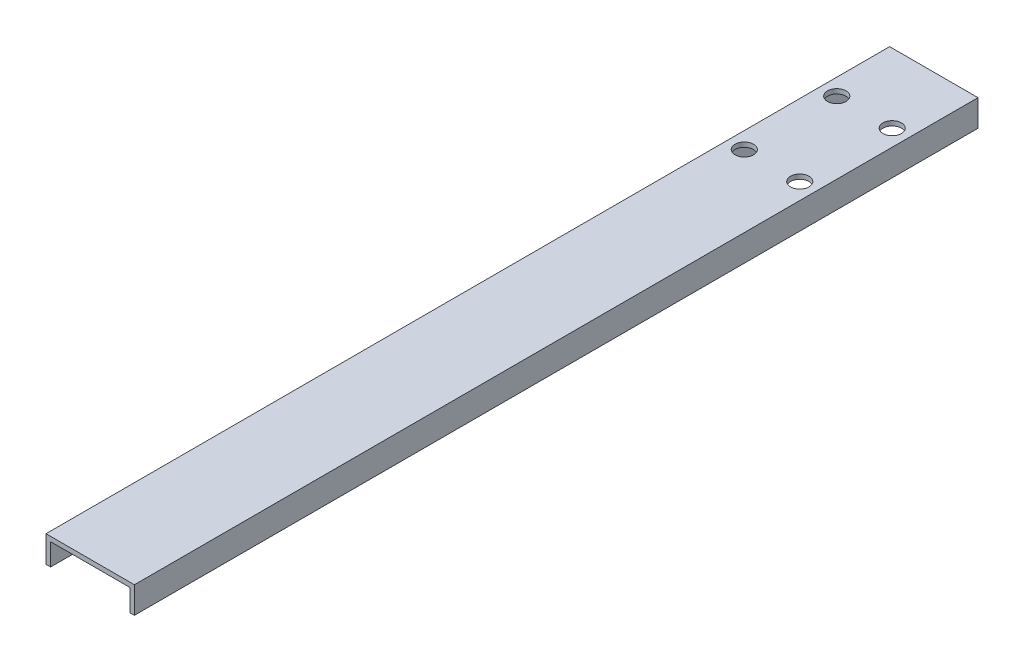
from build123d import *

# Parameters (mm, degrees)
BOSS_EXTRUDE1_DEPTH = 231.775
SKETCH2_R           = 2.54
CUT_EXTRUDE1_DEPTH  = 8.2898


with BuildPart() as part:
    # Sketch1 → Boss-Extrude1 (new body)
    with BuildSketch(Plane.XY):
        Polygon((0, 0), (0, 7.2898), (24.2824, 7.2898), (24.2824, 0), (23.0124, 0), (23.0124, 6.0198), (1.27, 6.0198), (1.27, 0), align=None)
    extrude(amount=BOSS_EXTRUDE1_DEPTH)

    # Sketch2 → Cut-Extrude1 (cut, through all)
    with BuildSketch(Plane(origin=(0, 7.2898, 0), x_dir=(1, 0, 0), z_dir=(0, 1, 0))):
        with Locations((4.5212, -19.05)):
            Circle(SKETCH2_R)
        with Locations((19.7612, -19.05)):
            Circle(SKETCH2_R)
        with Locations((19.7612, -44.45)):
            Circle(SKETCH2_R)
        with Locations((4.5212, -44.45)):
            Circle(SKETCH2_R)
    extrude(amount=-CUT_EXTRUDE1_DEPTH, mode=Mode.SUBTRACT)


solid = part.part
